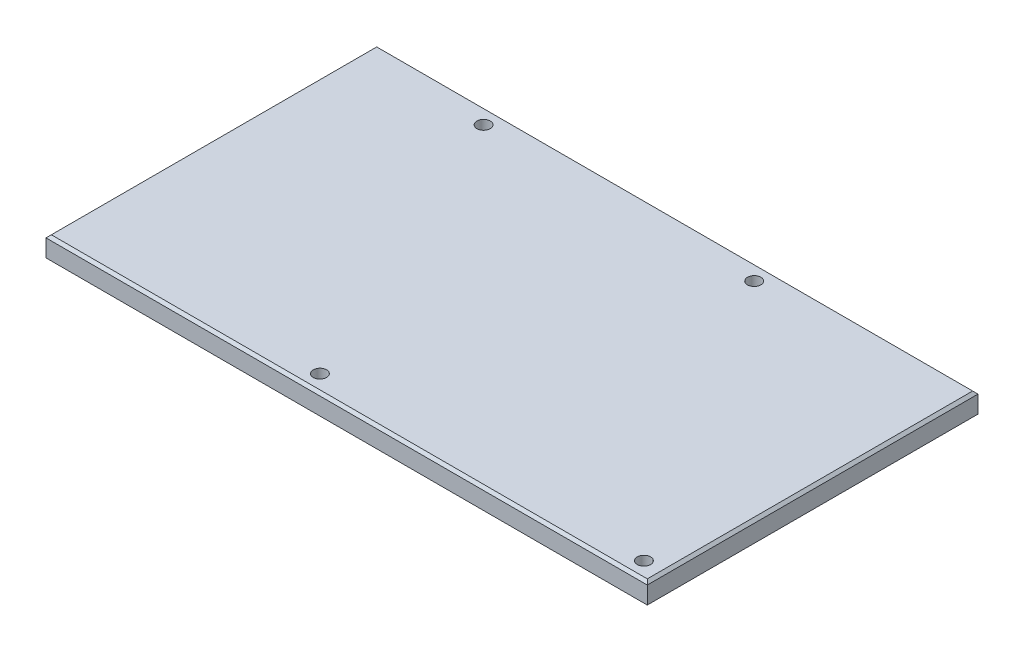
from build123d import *

# Parameters (mm, degrees)
SKETCH1_W                = 180
SKETCH1_H                = 99
BOSS_EXTRUDE1_DEPTH      = 6
F_4_0_4_DIAMETER_HOLE1_D = 4
F_4_0_4_DIAMETER_HOLE2_D = 4
LPATTERN1_COUNT          = 2
LPATTERN1_PITCH          = 97
LPATTERN2_COUNT          = 2
LPATTERN2_PITCH          = 81
CHAMFER1_SIZE            = 0.8


with BuildPart() as part:
    # Sketch1 → Boss-Extrude1 (new body)
    with BuildSketch(Plane(origin=(0, 0, 0), x_dir=(1, 0, 0), z_dir=(0, 1, 0))):
        with Locations((27.155172414, -14.50862069)):
            Rectangle(SKETCH1_W, SKETCH1_H)
    extrude(amount=BOSS_EXTRUDE1_DEPTH)

    # Ø4.0 (4) Diameter Hole1 (through all)
    with Locations(Plane(origin=(0, 6, 0), x_dir=(1, 0, 0), z_dir=(0, 1, 0))):
        with Locations((111.155172414, -59.00862069)):
            f_4_0_4_diameter_hole1 = Hole(F_4_0_4_DIAMETER_HOLE1_D / 2)

    # Ø4.0 (4) Diameter Hole2 (through all)
    with Locations(Plane(origin=(0, 6, 0), x_dir=(1, 0, 0), z_dir=(0, 1, 0))):
        with Locations((55.155172414, 29.99137931)):
            f_4_0_4_diameter_hole2 = Hole(F_4_0_4_DIAMETER_HOLE2_D / 2)

    # LPattern1: Ø4.0 (4) Diameter Hole1 ×2
    with Locations(*[(-i * LPATTERN1_PITCH, 0, 0) for i in range(1, LPATTERN1_COUNT)]):
        add(f_4_0_4_diameter_hole1, mode=Mode.SUBTRACT)

    # LPattern2: Ø4.0 (4) Diameter Hole2 ×2
    with Locations(*[(-i * LPATTERN2_PITCH, 0, 0) for i in range(1, LPATTERN2_COUNT)]):
        add(f_4_0_4_diameter_hole2, mode=Mode.SUBTRACT)

    # Chamfer1
    chamfer1_edges = [part.edges().sort_by_distance(p)[0] for p in [
        (117.155172414, 6, 14.50862069),
        (27.155172414, 6, -34.99137931),
        (-62.844827586, 6, 14.50862069),
        (27.155172414, 6, 64.00862069),
    ]]
    chamfer(chamfer1_edges, length=CHAMFER1_SIZE)


solid = part.part
